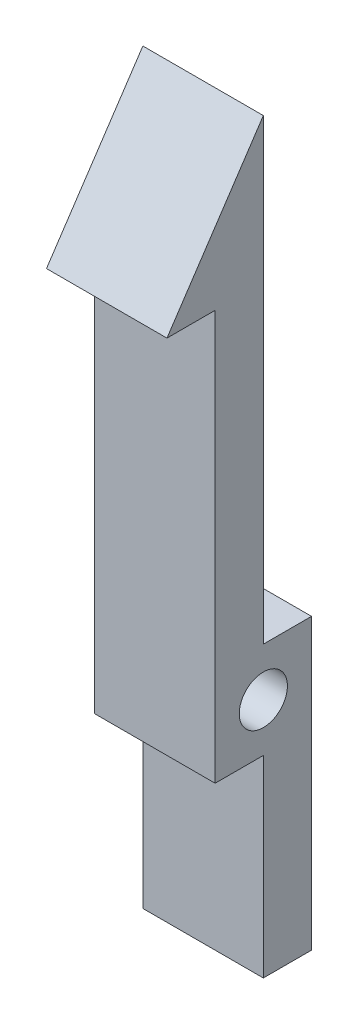
from build123d import *

# Parameters (mm, degrees)
SKIZZE1_R               = 1
LINEAR_AUSTRAGEN1_DEPTH = 2.5


with BuildPart() as part:
    # Skizze1 → Linear austragen1 (new body, symmetric)
    with BuildSketch(Plane(origin=(0, 0, 0), x_dir=(0, 0, -1), z_dir=(1, 0, 0))):
        Polygon((0, 21), (-4, 15), (-2, 15), (-2, -2), (0, -2), (0, -10), (2, -10), (2, 2), (0, 2), align=None)
        Circle(SKIZZE1_R, mode=Mode.SUBTRACT)
    extrude(amount=LINEAR_AUSTRAGEN1_DEPTH, both=True)


solid = part.part
